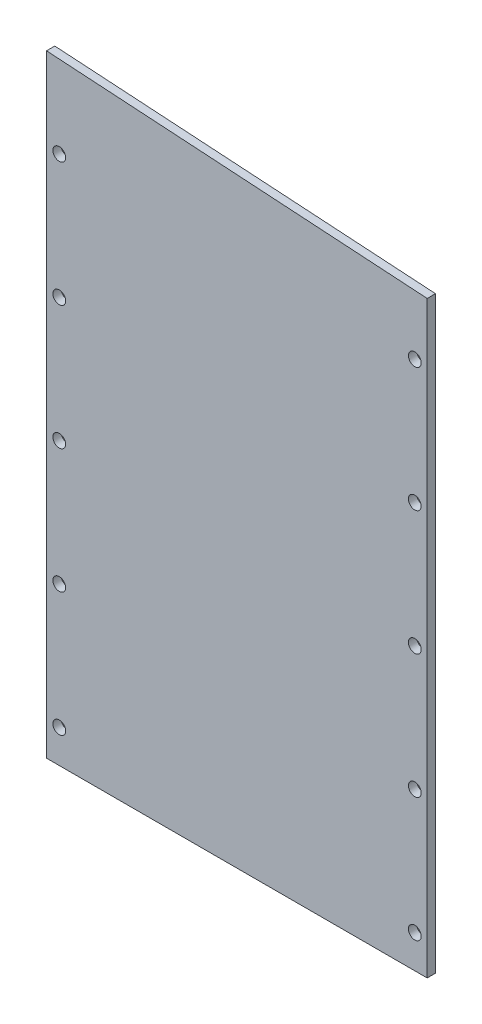
from build123d import *

# Parameters (mm, degrees)
BOSS_EXTRUDE1_DEPTH       = 3.175
F_8_CLEARANCE_HOLE1_D     = 4.9149
F_8_CLEARANCE_HOLE1_DEPTH = 3.175


with BuildPart() as part:
    # Sketch1 → Boss-Extrude1 (new body)
    with BuildSketch(Plane.XY):
        Polygon((-829.363556946, 6406.612895041), (-975.413556946, 6406.612895041), (-975.413556946, 6641.646276193), (-829.363556946, 6632.389598842), align=None)
    extrude(amount=BOSS_EXTRUDE1_DEPTH)

    # #8 Clearance Hole1
    with Locations(Plane.XY.offset(3.175)):
        with Locations((-970.524056946, 6609.812895041), (-970.524056946, 6562.187895041), (-970.524056946, 6514.562895041), (-970.524056946, 6466.937895041), (-970.524056946, 6419.312895041), (-834.126056946, 6419.312895041), (-834.126056946, 6466.937895041), (-834.126056946, 6514.562895041), (-834.126056946, 6562.187895041), (-834.126056946, 6609.812895041)):
            Hole(F_8_CLEARANCE_HOLE1_D / 2, depth=F_8_CLEARANCE_HOLE1_DEPTH)


solid = part.part
